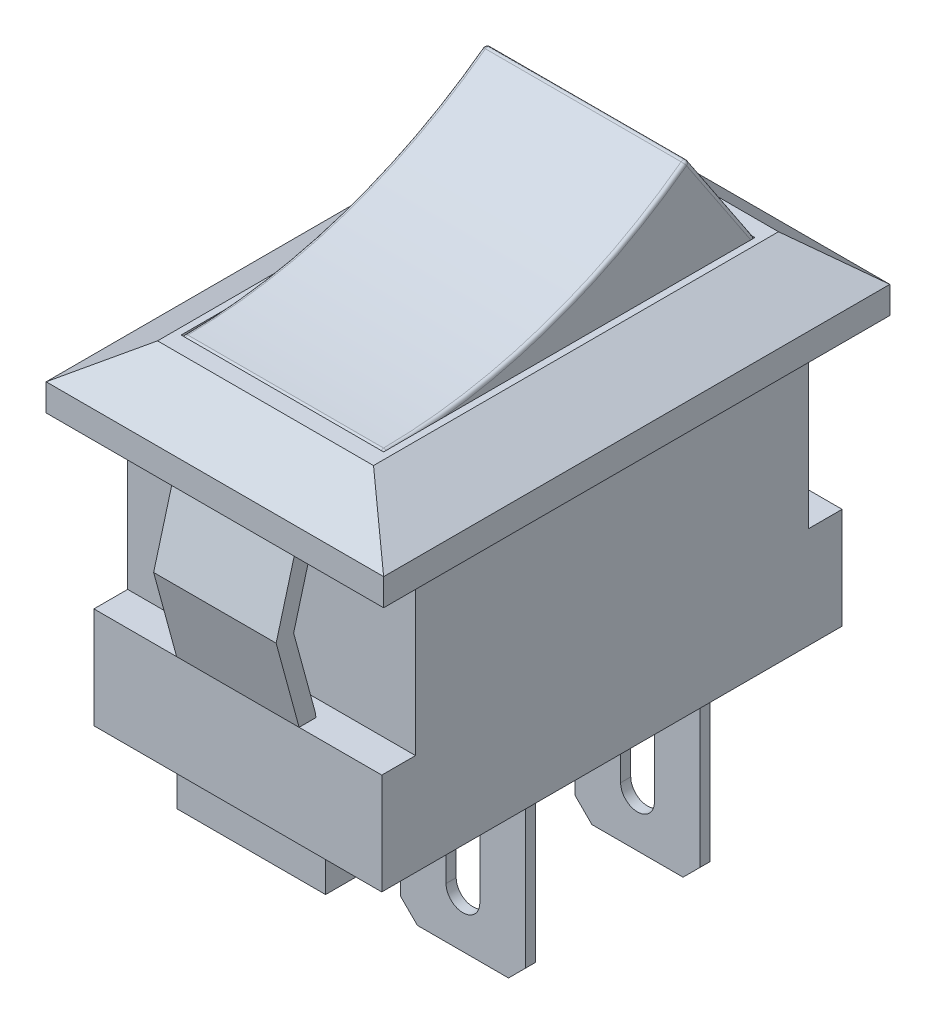
from build123d import *

# Parameters (mm, degrees)
SKETCH1_W           = 8.53
SKETCH1_H           = 13.64
BOSS_EXTRUDE1_DEPTH = 10
SKETCH2_W           = 1
SKETCH2_H           = 5
CUT_EXTRUDE1_DEPTH  = 9.53
SKETCH3_W           = 6
SKETCH3_H           = 11
CUT_EXTRUDE2_DEPTH  = 0.5
BOSS_EXTRUDE2_START = -2
SKETCH4_W           = 10
SKETCH4_H           = 15
SKETCH4_W_2         = 8.53
SKETCH4_H_2         = 13.64
SKETCH4_W_3         = 6
SKETCH4_H_3         = 11
BOSS_EXTRUDE2_DEPTH = 2
CHAMFER1_SIZE       = 1.5
CHAMFER1_SIZE2      = 1.2
CHAMFER2_SIZE       = 1.2
CHAMFER2_SIZE2      = 1.5
CHAMFER3_SIZE       = 1.8
CHAMFER3_SIZE2      = 1.2
CHAMFER4_SIZE       = 1.2
CHAMFER4_SIZE2      = 1.8
BOSS_EXTRUDE3_DEPTH = 1.815
SKETCH7_W           = 7
SKETCH7_H           = 2.5
BOSS_EXTRUDE4_DEPTH = 0.3
BOSS_EXTRUDE5_DEPTH = 1
SKETCH8_5_W         = 5
SKETCH8_5_H         = 0.4
SKETCH8_5_W_2       = 3.4
SKETCH8_5_H_2       = 1.5
CUT_EXTRUDE4_DEPTH  = 1
BOSS_EXTRUDE6_DEPTH = 0.15
LPATTERN1_COUNT     = 2
LPATTERN1_PITCH     = 5.1725
BOSS_EXTRUDE7_DEPTH = 3
FILLET1_R           = 0.1


with BuildPart() as part:
    # Sketch1 → Boss-Extrude1 (new body)
    with BuildSketch(Plane(origin=(0, 0, 0), x_dir=(1, 0, 0), z_dir=(0, 1, 0))):
        Rectangle(SKETCH1_W, SKETCH1_H)
    extrude(amount=BOSS_EXTRUDE1_DEPTH)

    # Sketch2 → Cut-Extrude1 (cut, through all)
    with BuildSketch(Plane.ZY.offset(4.265)):
        with Locations((-6.32, 5.5)):
            Rectangle(SKETCH2_W, SKETCH2_H)
        with Locations((6.32, 5.5)):
            Rectangle(SKETCH2_W, SKETCH2_H)
    extrude(amount=-CUT_EXTRUDE1_DEPTH, mode=Mode.SUBTRACT)

    # Sketch3 → Cut-Extrude2 (cut)
    with BuildSketch(Plane(origin=(0, 10, 0), x_dir=(1, 0, 0), z_dir=(0, 1, 0))):
        Rectangle(SKETCH3_W, SKETCH3_H)
    extrude(amount=-CUT_EXTRUDE2_DEPTH, mode=Mode.SUBTRACT)

    # Sketch4 → Boss-Extrude2 (add)
    with BuildSketch(Plane(origin=(0, 10, 0), x_dir=(1, 0, 0), z_dir=(0, 1, 0)).offset(BOSS_EXTRUDE2_START)):
        Rectangle(SKETCH4_W, SKETCH4_H)
        Rectangle(SKETCH4_W_2, SKETCH4_H_2, mode=Mode.SUBTRACT)
        Rectangle(SKETCH4_W_2, SKETCH4_H_2)
        Rectangle(SKETCH4_W_3, SKETCH4_H_3, mode=Mode.SUBTRACT)
    extrude(amount=BOSS_EXTRUDE2_DEPTH)

    # Chamfer1
    chamfer1_edges = [part.edges().sort_by_distance(p)[0] for p in [
        (0, 10, 7.5),
    ]]
    chamfer1_side = [part.faces().sort_by_distance(p)[0] for p in [
        (-4.819722436, 10, 0),
    ]]
    chamfer(chamfer1_edges, length=CHAMFER1_SIZE, length2=CHAMFER1_SIZE2, reference=chamfer1_side[0])

    # Chamfer2
    chamfer2_edges = [part.edges().sort_by_distance(p)[0] for p in [
        (0, 10, -7.5),
    ]]
    chamfer2_side = [part.faces().sort_by_distance(p)[0] for p in [
        (0, 9, -7.5),
    ]]
    chamfer(chamfer2_edges, length=CHAMFER2_SIZE, length2=CHAMFER2_SIZE2, reference=chamfer2_side[0])

    # Chamfer3
    chamfer3_edges = [part.edges().sort_by_distance(p)[0] for p in [
        (-5, 10, 0),
    ]]
    chamfer3_side = [part.faces().sort_by_distance(p)[0] for p in [
        (-4.843795006, 10, 0),
    ]]
    chamfer(chamfer3_edges, length=CHAMFER3_SIZE, length2=CHAMFER3_SIZE2, reference=chamfer3_side[0])

    # Chamfer4
    chamfer4_edges = [part.edges().sort_by_distance(p)[0] for p in [
        (5, 10, 0),
    ]]
    chamfer4_side = [part.faces().sort_by_distance(p)[0] for p in [
        (5, 8.961702128, 0),
    ]]
    chamfer(chamfer4_edges, length=CHAMFER4_SIZE, length2=CHAMFER4_SIZE2, reference=chamfer4_side[0])

    # Sketch6 → Boss-Extrude3 (add, symmetric)
    with BuildSketch(Plane(origin=(0, 0, 0), x_dir=(0, 0, -1), z_dir=(1, 0, 0))):
        Polygon((-6.82, 8), (-7.5, 5.5), (-6.82, 3), (-6.32, 3), (-6.337529128, 3.131232077), (-6.981834003, 5.5), (-6.337529128, 7.868767923), (-6.337529128, 8), align=None)
        Polygon((6.32, 3), (6.82, 3), (7.5, 5.5), (6.82, 8), (6.337529128, 8), (6.337529128, 7.868767923), (6.981834003, 5.5), (6.337529128, 3.131232077), align=None)
    extrude(amount=BOSS_EXTRUDE3_DEPTH, both=True)

    # Sketch7 → Boss-Extrude4 (add)
    with BuildSketch(Plane.XZ):
        Rectangle(SKETCH7_W, SKETCH7_H)
        with Locations((0, -5.17)):
            Rectangle(SKETCH7_W, SKETCH7_H)
        with Locations((0, 5.17)):
            Rectangle(SKETCH7_W, SKETCH7_H)
    extrude(amount=BOSS_EXTRUDE4_DEPTH)

    # Sketch8 → Boss-Extrude5 (add)
    with BuildSketch(Plane.XZ.offset(0.3)):
        Polygon((1.7, 5.37), (2.2, 5.37), (2.2, 6.42), (-2.2, 6.42), (-2.2, 5.37), (-1.7, 5.37), (-1.7, 5.92), (1.7, 5.92), align=None)
        Polygon((-2.2, 3.92), (2.2, 3.92), (2.2, 4.97), (1.7, 4.97), (1.7, 4.42), (-1.7, 4.42), (-1.7, 4.97), (-2.2, 4.97), align=None)
        Polygon((1.7, 0.2), (2.2, 0.2), (2.2, 1.25), (-2.2, 1.25), (-2.2, 0.2), (-1.7, 0.2), (-1.7, 0.75), (1.7, 0.75), align=None)
        Polygon((-2.2, -1.25), (2.2, -1.25), (2.2, -0.2), (1.7, -0.2), (1.7, -0.75), (-1.7, -0.75), (-1.7, -0.2), (-2.2, -0.2), align=None)
        Polygon((1.7, -4.97), (2.2, -4.97), (2.2, -3.92), (-2.2, -3.92), (-2.2, -4.97), (-1.7, -4.97), (-1.7, -4.42), (1.7, -4.42), align=None)
        Polygon((-2.2, -6.42), (2.2, -6.42), (2.2, -5.37), (1.7, -5.37), (1.7, -5.92), (-1.7, -5.92), (-1.7, -5.37), (-2.2, -5.37), align=None)
    extrude(amount=BOSS_EXTRUDE5_DEPTH)

    # Sketch8_5 → Cut-Extrude4 (cut)
    with BuildSketch(Plane.XZ.offset(0.3)):
        Rectangle(SKETCH8_5_W, SKETCH8_5_H)
        with Locations((0, -5.17)):
            Rectangle(SKETCH8_5_W, SKETCH8_5_H)
        with Locations((0, 5.17)):
            Rectangle(SKETCH8_5_W, SKETCH8_5_H)
        with Locations((0, 5.17)):
            Rectangle(SKETCH8_5_W_2, SKETCH8_5_H_2)
        Rectangle(SKETCH8_5_W_2, SKETCH8_5_H_2)
        with Locations((0, -5.17)):
            Rectangle(SKETCH8_5_W_2, SKETCH8_5_H_2)
    extrude(amount=-CUT_EXTRUDE4_DEPTH, mode=Mode.SUBTRACT)

    # Sketch10 → Boss-Extrude6 (add, symmetric)
    with BuildSketch(Plane.XY):
        Polygon((1.85, -1.65), (1.85, -1.3), (-1.85, -1.3), (-1.85, -1.65), (-1.85, -6.5), (-1.35, -7), (1.35, -7), (1.85, -6.5), align=None)
        with BuildLine():
            ThreePointArc((0.5, -5.5), (0, -6), (-0.5, -5.5))
            Line((-0.5, -5.5), (-0.5, -3.7))
            ThreePointArc((-0.5, -3.7), (0, -3.2), (0.5, -3.7))
            Line((0.5, -3.7), (0.5, -5.5))
        make_face(mode=Mode.SUBTRACT)
        Polygon((2.5, 0), (1.85, 0), (-1.85, 0), (-2.5, 0), (-2.5, -0.3), (-2.2, -0.3), (-2.2, -1.3), (-1.85, -1.3), (1.85, -1.3), (2.2, -1.3), (2.2, -0.3), (2.5, -0.3), align=None)
    boss_extrude6 = extrude(amount=BOSS_EXTRUDE6_DEPTH, both=True)

    # LPattern1: Boss-Extrude6 ×2
    with Locations(*[(0, 0, -i * LPATTERN1_PITCH) for i in range(1, LPATTERN1_COUNT)]):
        add(boss_extrude6)


with BuildPart() as body_2:
    # Sketch11 → Boss-Extrude7 (new body, symmetric)
    with BuildSketch(Plane(origin=(0, 0, 0), x_dir=(0, 0, -1), z_dir=(1, 0, 0))):
        with BuildLine():
            Line((5.5, 9.5), (-5.5, 9.5))
            Line((-5.5, 9.5), (-5.5, 9.900331129))
            ThreePointArc((-5.5, 9.900331129), (-5.470944433, 9.970807277), (-5.400662252, 10.000328937))
            ThreePointArc((-5.400662252, 10.000328937), (-0.759264413, 10.768857175), (3.415788118, 12.937300375))
            ThreePointArc((3.415788118, 12.937300375), (3.492454919, 12.955387143), (3.558431735, 12.912352398))
            Line((3.558431735, 12.912352398), (5.483205029, 10.025192456))
            ThreePointArc((5.483205029, 10.025192456), (5.495709203, 9.998700851), (5.5, 9.969722436))
            Line((5.5, 9.969722436), (5.5, 9.5))
        make_face()
    extrude(amount=BOSS_EXTRUDE7_DEPTH, both=True)

    # Fillet1
    fillet1_edges = [body_2.edges().sort_by_distance(p)[0] for p in [
        (-3, 12.955387143, -3.492454919),
        (-3, 11.468772427, -4.520818382),
        (-3, 9.998700851, -5.495709203),
        (-3, 9.734861218, -5.5),
        (3, 11.468772427, -4.520818382),
        (3, 12.955387143, -3.492454919),
        (3, 10.768857175, 0.759264413),
        (3, 9.970807277, 5.470944433),
        (3, 9.700165565, 5.5),
        (3, 9.734861218, -5.5),
        (3, 9.998700851, -5.495709203),
        (-3, 9.700165565, 5.5),
        (-3, 9.970807277, 5.470944433),
        (-3, 10.768857175, 0.759264413),
    ]]
    fillet(fillet1_edges, radius=FILLET1_R)


solid = Compound([part.part, body_2.part])
